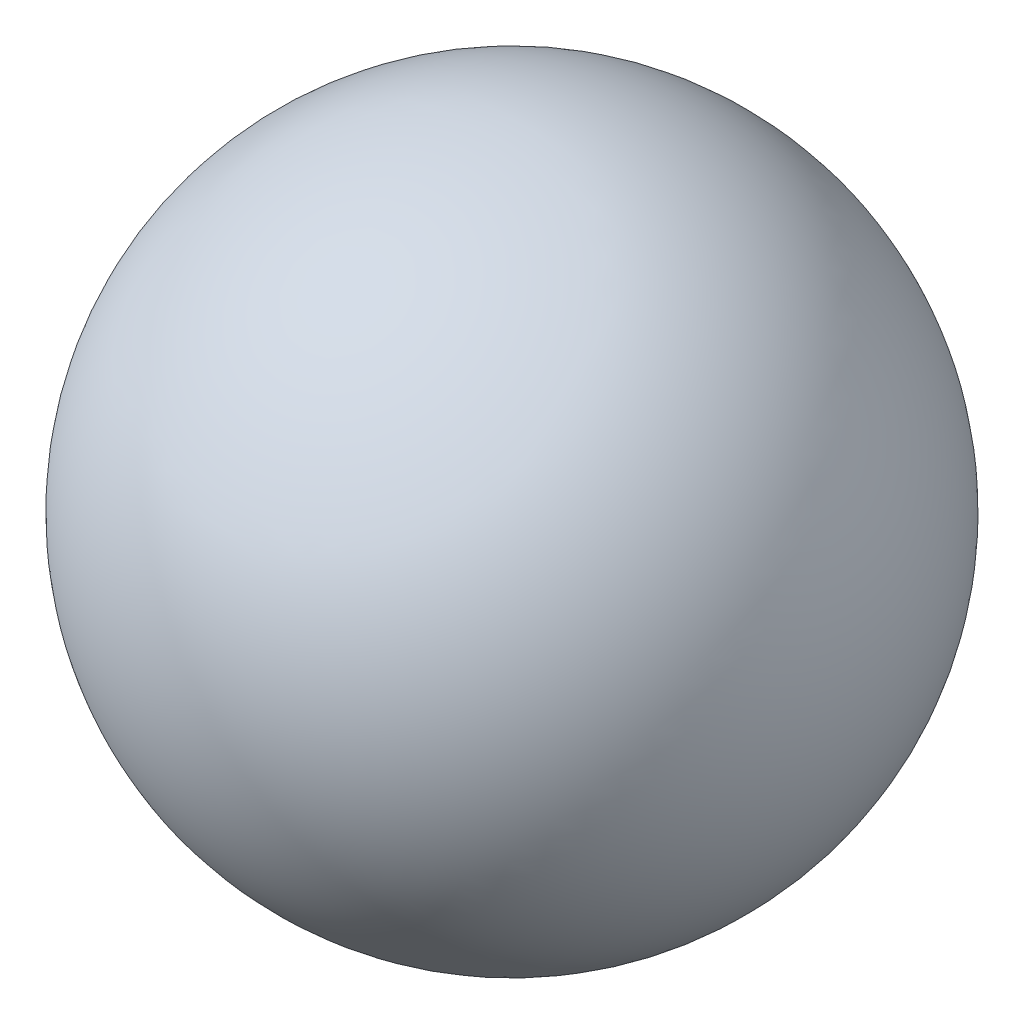
from build123d import *


with BuildPart() as part:
    # Sketch1 one side → Revolve4 (revolve)
    with BuildSketch(Plane(origin=(0, 0, 0), x_dir=(1, 0, 0), z_dir=(0, 1, 0))):
        with BuildLine():
            ThreePointArc((0, -6.35), (4.490128061, -4.490128061), (6.35, 0))
            ThreePointArc((6.35, 0), (4.490128061, 4.490128061), (0, 6.35))
            Line((0, 6.35), (0, -6.35))
        make_face()
    revolve(axis=Axis((0, 0, -11.17992278), (0, 0, 1)))


solid = part.part
